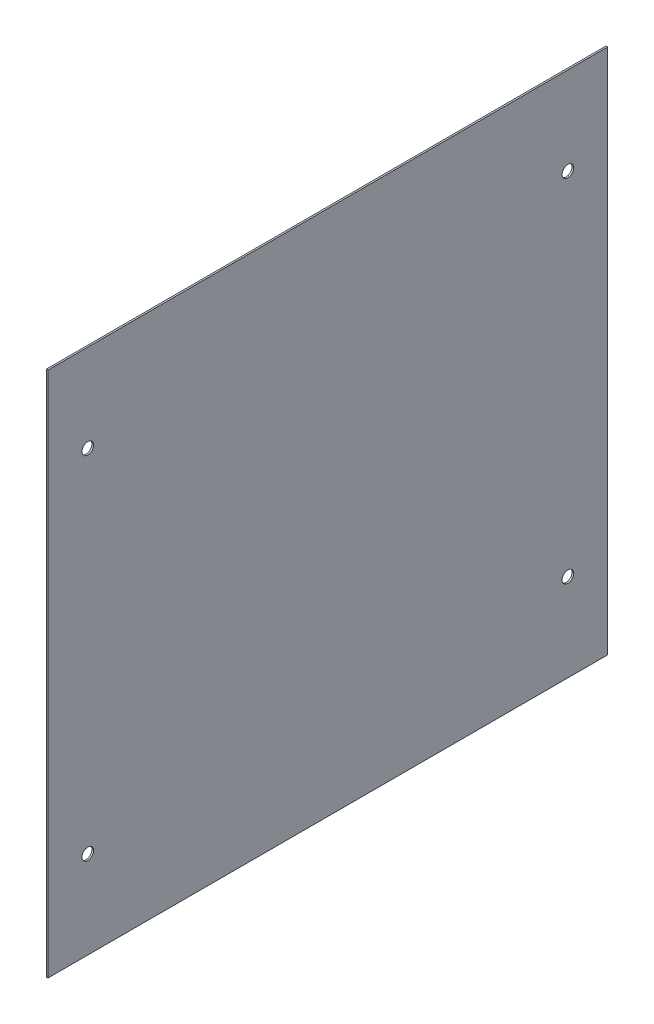
from build123d import *

# Parameters (mm, degrees)
SKETCH1_W           = 338
SKETCH1_H           = 318
SKETCH1_R           = 3.5
BOSS_EXTRUDE1_DEPTH = 1


with BuildPart() as part:
    # Sketch1 → Boss-Extrude1 (new body)
    with BuildSketch(Plane(origin=(0, 0, 0), x_dir=(0, 0, -1), z_dir=(1, 0, 0))):
        with Locations((169, 159)):
            Rectangle(SKETCH1_W, SKETCH1_H)
        with Locations((24, 265.06)):
            Circle(SKETCH1_R, mode=Mode.SUBTRACT)
        with Locations((314, 265.06)):
            Circle(SKETCH1_R, mode=Mode.SUBTRACT)
        with Locations((314, 52.94)):
            Circle(SKETCH1_R, mode=Mode.SUBTRACT)
        with Locations((24, 52.94)):
            Circle(SKETCH1_R, mode=Mode.SUBTRACT)
    extrude(amount=BOSS_EXTRUDE1_DEPTH)


solid = part.part
